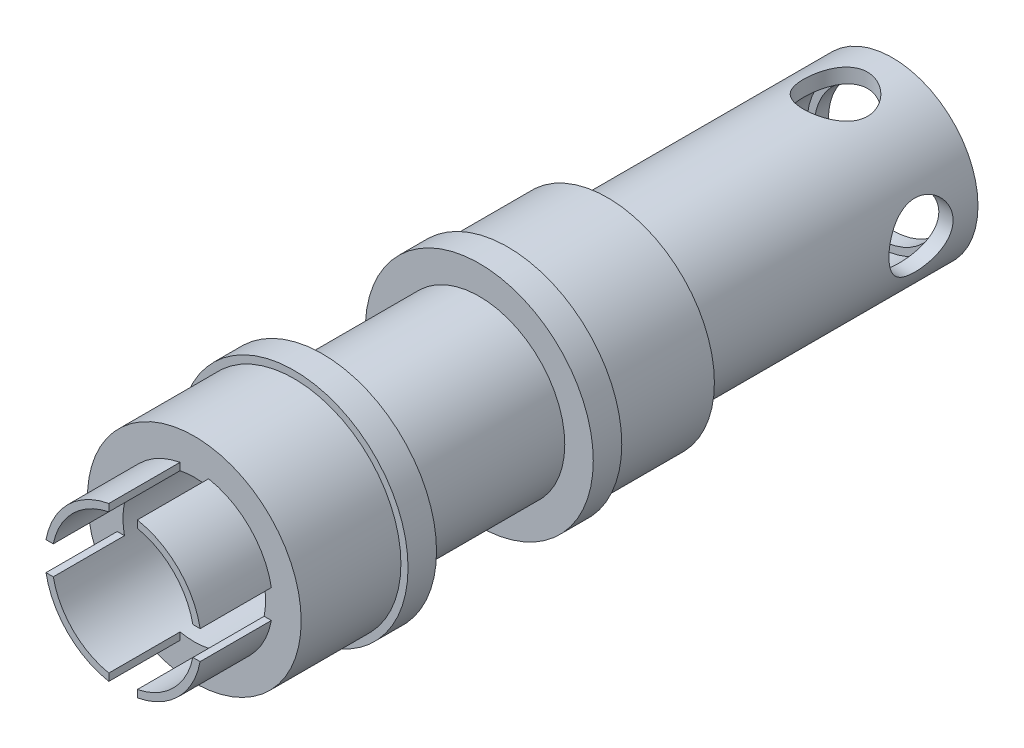
from build123d import *

# Parameters (mm, degrees)
ESQUISSE1_R                = 6
ESQUISSE1_R_2              = 5
BOSS_EXTRU_1_DEPTH         = 20
ESQUISSE2_R                = 6
ESQUISSE2_R_2              = 4.5
BOSS_EXTRU_2_DEPTH         = 1
ESQUISSE3_R                = 7.5
ESQUISSE3_R_2              = 5
BOSS_EXTRU_3_DEPTH         = 7
ESQUISSE4_R                = 8
ESQUISSE4_R_2              = 5
BOSS_EXTRU_4_DEPTH         = 2
ESQUISSE7_R                = 6
ESQUISSE7_R_2              = 5
BOSS_EXTRU_7_DEPTH         = 11
ESQUISSE8_R                = 8
ESQUISSE8_R_2              = 5
BOSS_EXTRU_8_DEPTH         = 2
D_GAGEMENT_M41_D           = 4.5
D_GAGEMENT_M41_ON_FACE_2_D = 4.5
ESQUISSE15_R               = 7.5
ESQUISSE15_R_2             = 5
BOSS_EXTRU_9_DEPTH         = 7
ESQUISSE16_R               = 5.5
ESQUISSE16_R_2             = 5
BOSS_EXTRU_10_DEPTH        = 5
ESQUISSE17_W               = 20
ESQUISSE17_H               = 2
ESQUISSE17_W_2             = 2
ESQUISSE17_H_2             = 20
ENL_V_MAT_EXTRU_1_DEPTH    = 5


with BuildPart() as part:
    # Esquisse1 → Boss.-Extru.1 (new body)
    with BuildSketch(Plane.XY):
        Circle(ESQUISSE1_R)
        Circle(ESQUISSE1_R_2, mode=Mode.SUBTRACT)
    extrude(amount=BOSS_EXTRU_1_DEPTH)

    # Esquisse2 → Boss.-Extru.2 (add)
    with BuildSketch(Plane(origin=(0, 0, 0), x_dir=(-1, 0, 0), z_dir=(0, 0, -1))):
        Circle(ESQUISSE2_R)
        Circle(ESQUISSE2_R_2, mode=Mode.SUBTRACT)
    extrude(amount=-BOSS_EXTRU_2_DEPTH)

    # Esquisse3 → Boss.-Extru.3 (add)
    with BuildSketch(Plane.XY.offset(20)):
        Circle(ESQUISSE3_R)
        Circle(ESQUISSE3_R_2, mode=Mode.SUBTRACT)
    extrude(amount=BOSS_EXTRU_3_DEPTH)

    # Esquisse4 → Boss.-Extru.4 (add)
    with BuildSketch(Plane.XY.offset(27)):
        Circle(ESQUISSE4_R)
        Circle(ESQUISSE4_R_2, mode=Mode.SUBTRACT)
    extrude(amount=BOSS_EXTRU_4_DEPTH)

    # Esquisse7 → Boss.-Extru.7 (add)
    with BuildSketch(Plane.XY.offset(29)):
        Circle(ESQUISSE7_R)
        Circle(ESQUISSE7_R_2, mode=Mode.SUBTRACT)
    extrude(amount=BOSS_EXTRU_7_DEPTH)

    # Esquisse8 → Boss.-Extru.8 (add)
    with BuildSketch(Plane.XY.offset(40)):
        Circle(ESQUISSE8_R)
        Circle(ESQUISSE8_R_2, mode=Mode.SUBTRACT)
    extrude(amount=BOSS_EXTRU_8_DEPTH)

    # Dégagement M41 (through all)
    with Locations(Plane(origin=(6, 0, 4), x_dir=(0, 1, 0), z_dir=(1, 0, 0))):
        with Locations((0, 0)):
            Hole(D_GAGEMENT_M41_D / 2)

    # Dégagement M41 on face 2 (through all)
    with Locations(Plane(origin=(0, 6, 4), x_dir=(0, 0, 1), z_dir=(0, 1, 0))):
        with Locations((0, 0)):
            Hole(D_GAGEMENT_M41_ON_FACE_2_D / 2)

    # Esquisse15 → Boss.-Extru.9 (add)
    with BuildSketch(Plane.XY.offset(42)):
        Circle(ESQUISSE15_R)
        Circle(ESQUISSE15_R_2, mode=Mode.SUBTRACT)
    extrude(amount=BOSS_EXTRU_9_DEPTH)

    # Esquisse16 → Boss.-Extru.10 (add)
    with BuildSketch(Plane.XY.offset(49)):
        Circle(ESQUISSE16_R)
        Circle(ESQUISSE16_R_2, mode=Mode.SUBTRACT)
    extrude(amount=BOSS_EXTRU_10_DEPTH)

    # Esquisse17 → Enlèv. mat.-Extru.1 (cut)
    with BuildSketch(Plane.XY.offset(54)):
        Rectangle(ESQUISSE17_W, ESQUISSE17_H)
        Rectangle(ESQUISSE17_W_2, ESQUISSE17_H_2)
    extrude(amount=-ENL_V_MAT_EXTRU_1_DEPTH, mode=Mode.SUBTRACT)


solid = part.part
